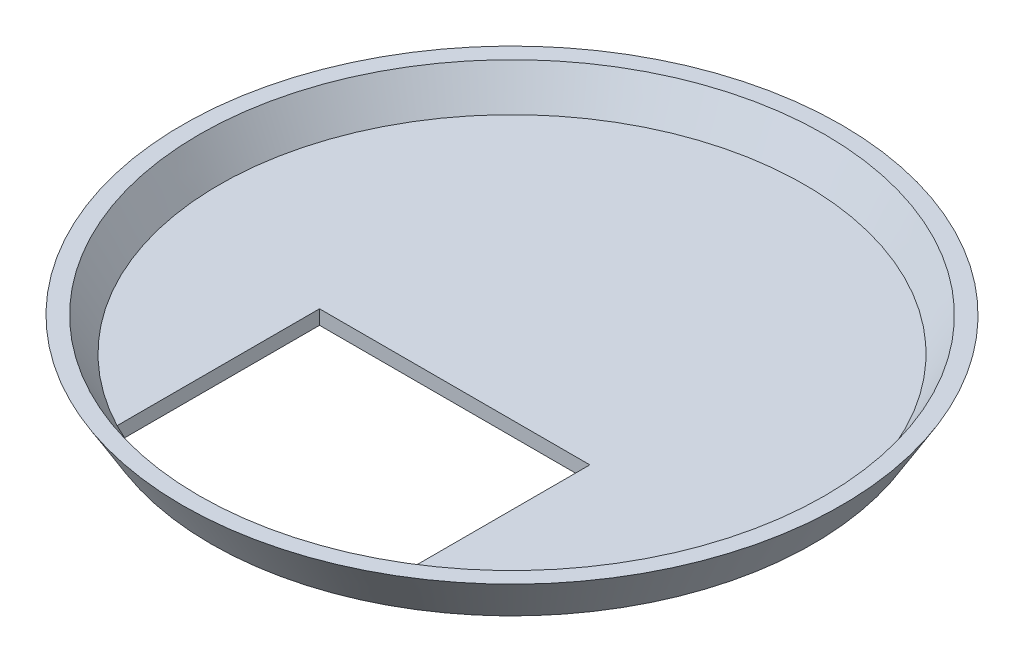
from build123d import *

# Parameters (mm, degrees)
CUT_EXTRUDE1_DEPTH = 4


with BuildPart() as part:
    # Sketch1 → Revolve1 (revolve)
    with BuildSketch(Plane.XY):
        Polygon((0, 0), (63, 0), (69, 10), (65.501428863, 10), (61.301428863, 3), (0, 3), align=None)
    revolve(axis=Axis((0, 0, 0), (0, 1, 0)))

    # Sketch2 → Cut-Extrude1 (cut, through all)
    with BuildSketch(Plane(origin=(0, 3, 0), x_dir=(1, 0, 0), z_dir=(0, 1, 0))):
        with BuildLine():
            Line((-28.3, -12), (-28.3, -54.378076287))
            ThreePointArc((-28.3, -54.378076287), (0, -61.301428863), (28.3, -54.378076287))
            Line((28.3, -54.378076287), (28.3, -12))
            Line((28.3, -12), (-28.3, -12))
        make_face()
    extrude(amount=-CUT_EXTRUDE1_DEPTH, mode=Mode.SUBTRACT)


solid = part.part
